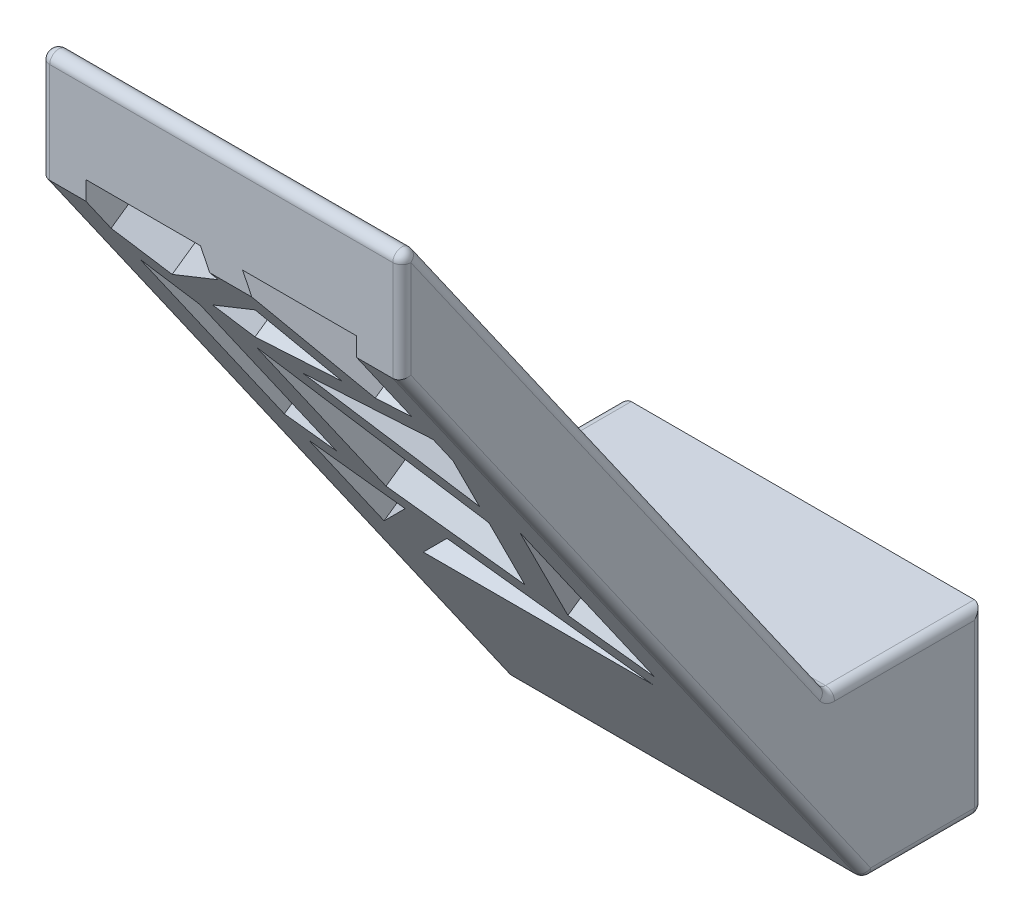
from build123d import *

# Parameters (mm, degrees)
SKETCH1_W           = 20
SKETCH1_H           = 10
BOSS_EXTRUDE1_DEPTH = 5
BOSS_EXTRUDE2_DEPTH = 20
CUT_EXTRUDE1_DEPTH  = 4.09576
FILLET1_R           = 0.5


with BuildPart() as part:
    # Sketch1 → Boss-Extrude1 (new body)
    with BuildSketch(Plane.XY):
        with Locations((-83, 16.5)):
            Rectangle(SKETCH1_W, SKETCH1_H)
    extrude(amount=BOSS_EXTRUDE1_DEPTH)

    # Sketch2 → Boss-Extrude2 (add)
    with BuildSketch(Plane.ZY.offset(93)):
        Polygon((5, 16.5), (1.498962309, 11.5), (6.498962309, 11.5), (32.208054955, 48.216389418), (32.208054955, 55.357129452), (8.501037691, 21.5), (5, 21.5), align=None)
    extrude(amount=-BOSS_EXTRUDE2_DEPTH)

    # Sketch3 → Cut-Extrude1 (cut)
    with BuildSketch(Plane(origin=(0, 3.079102266, -4.397413763), x_dir=(-1, 0, 0), z_dir=(0, 0.573576436, -0.819152044))):
        Polygon((90.5, 29.170685305), (90.5, 36.425657649), (86.606804382, 33.925761075), align=None)
        Polygon((76.580636571, 27.487763856), (89.293048323, 27.487763856), (84.912643674, 32.837907557), align=None)
        Polygon((79.020661139, 31.431370249), (75.5, 42.221469006), (75.5, 29.170685305), align=None)
        Polygon((83.682826439, 48.850072065), (75.5, 50.589500561), (75.5, 48.669091242), (77.437703633, 42.730430083), align=None)
        Polygon((77.812370658, 52.142645531), (81.816362113, 58.81968714), (75.5, 58.81968714), (75.5, 52.634187597), align=None)
        Polygon((90.5, 55.53027081), (90.5, 58.81968714), (84.148398738, 58.81968714), (83.395113947, 57.563512158), (88.334689519, 53.40846707), align=None)
        Polygon((86.899562452, 52.002175453), (85.397480311, 50.530274064), (79.880748536, 51.702969161), (82.353375162, 55.826312344), align=None)
        Polygon((90.5, 38.802476843), (90.5, 52.730114749), (88.38308654, 50.655735608), (88.38308654, 37.443165566), align=None)
        Polygon((86.38308654, 36.158926695), (80.76001209, 32.548241301), (78.130006045, 40.608666271), (86.38308654, 48.69592083), align=None)
    extrude(amount=-CUT_EXTRUDE1_DEPTH, mode=Mode.SUBTRACT)

    # Fillet1
    fillet1_edges = [part.edges().sort_by_distance(p)[0] for p in [
        (-88.38308654, 39.162299764, 20.868313128),
        (-90.5, 40.568657026, 21.853055085),
        (-89.44154327, 34.307489189, 17.468938167),
        (-89.44154327, 45.423467601, 25.252430045),
        (-85.864901733, 48.530564087, 27.428042427),
        (-90.5, 49.914103175, 28.396806926),
        (-87.324199369, 51.26136923, 29.340172774),
        (-89.41734476, 47.697797184, 26.844932764),
        (-83.771756342, 50.746870078, 28.979916589),
        (-84.626468807, 47.243065371, 26.526526121),
        (-81.117061849, 47.120517648, 26.440717281),
        (-82.639114423, 44.951387357, 24.9218759),
        (-86.148521381, 45.07393508, 25.007684739),
        (-88.553402191, 31.893356499, 15.778544259),
        (-88.553402191, 28.921893785, 13.697903667),
        (-90.5, 29.94579148, 14.414844551),
        (-83, 21.5, 8.501037691),
        (-83, 55.357129452, 32.208054955),
        (-83, 11.5, 6.498962309),
        (-93, 29.858194709, 19.353508632),
        (-93, 51.786759435, 32.208054955),
        (-93, 38.428564726, 20.354546323),
        (-73, 38.428564726, 20.354546323),
        (-73, 51.786759435, 32.208054955),
        (-73, 29.858194709, 19.353508632),
        (-83, 11.5, 0),
        (-93, 16.5, 0),
        (-73, 16.5, 0),
        (-80.560265036, 40.588280041, 21.866795268),
        (-76.468851816, 40.514154635, 21.814892099),
        (-79.59141322, 43.807166866, 24.120684086),
        (-75.5, 43.73304146, 24.068780918),
        (-73, 11.5, 3.249481154),
        (-93, 11.5, 3.249481154),
        (-76.656185329, 45.993180791, 25.651347516),
        (-79.814366386, 48.526613089, 27.425275908),
        (-93, 21.5, 4.250518846),
        (-78.658181056, 51.26136923, 29.340172774),
        (-75.5, 48.727936933, 27.566244381),
        (-73, 21.5, 4.250518846),
        (-87.102845999, 27.787050796, 12.903278052),
        (-80.746640123, 27.787050796, 12.903278052),
        (-82.936842447, 25.595760221, 11.368919873),
        (-77.26033057, 27.900251113, 12.982541767),
        (-77.26033057, 33.245539188, 16.725352771),
        (-75.5, 32.319616841, 16.077014963),
        (-86.38308654, 37.833613175, 19.937956762),
        (-82.256546293, 39.65611981, 21.214089647),
        (-79.445009068, 33.042417461, 16.583125407),
        (-83.571549315, 31.219910826, 15.306992522),
    ]]
    fillet(fillet1_edges, radius=FILLET1_R)


solid = part.part
